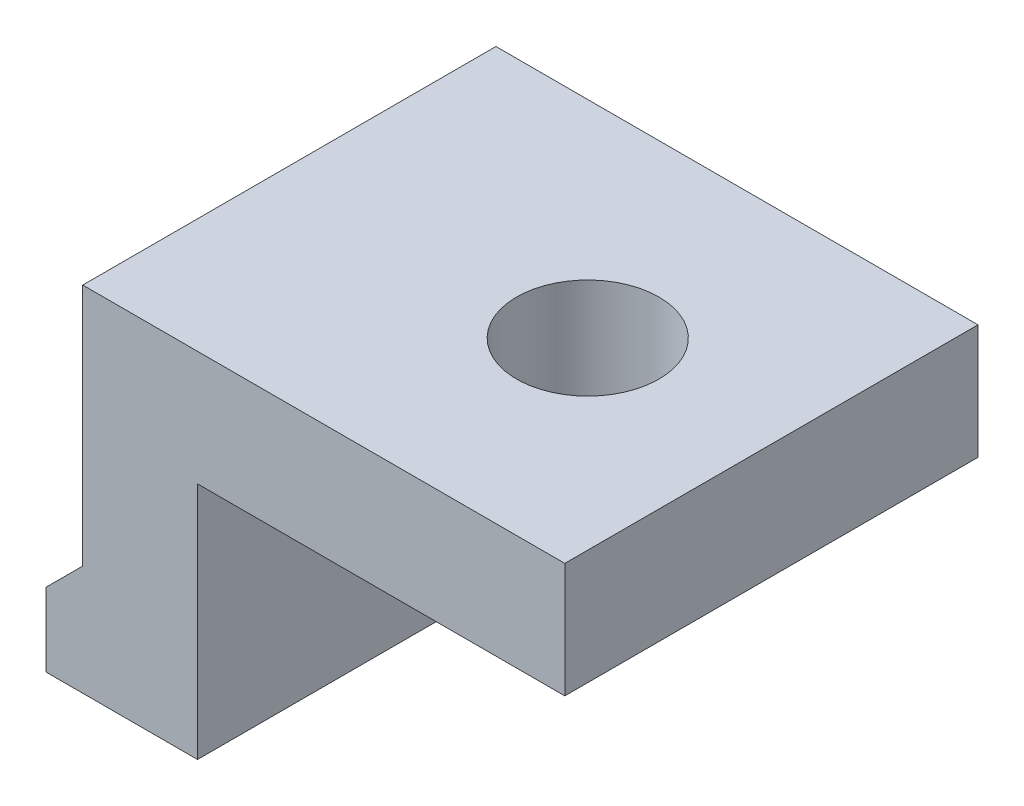
from build123d import *

# Parameters (mm, degrees)
SKETCH1_W           = 8
SKETCH1_H           = 2.5
BOSS_EXTRUDE1_DEPTH = 9
SKETCH2_R           = 1.55
CUT_EXTRUDE1_DEPTH  = 3.5


with BuildPart() as part:
    # Sketch1 → Boss-Extrude1 (new body)
    with BuildSketch(Plane.XY):
        with Locations((4, -1.25)):
            Rectangle(SKETCH1_W, SKETCH1_H)
        Polygon((0, -7.7), (0, 0), (-2.5, 0), (-2.5, -5.3), (-3.3, -6.1), (-3.3, -7.7), align=None)
    extrude(amount=BOSS_EXTRUDE1_DEPTH)

    # Sketch2 → Cut-Extrude1 (cut, through all)
    with BuildSketch(Plane.XZ.offset(2.5)):
        with Locations((4, 4.5)):
            Circle(SKETCH2_R)
    extrude(amount=-CUT_EXTRUDE1_DEPTH, mode=Mode.SUBTRACT)


solid = part.part
